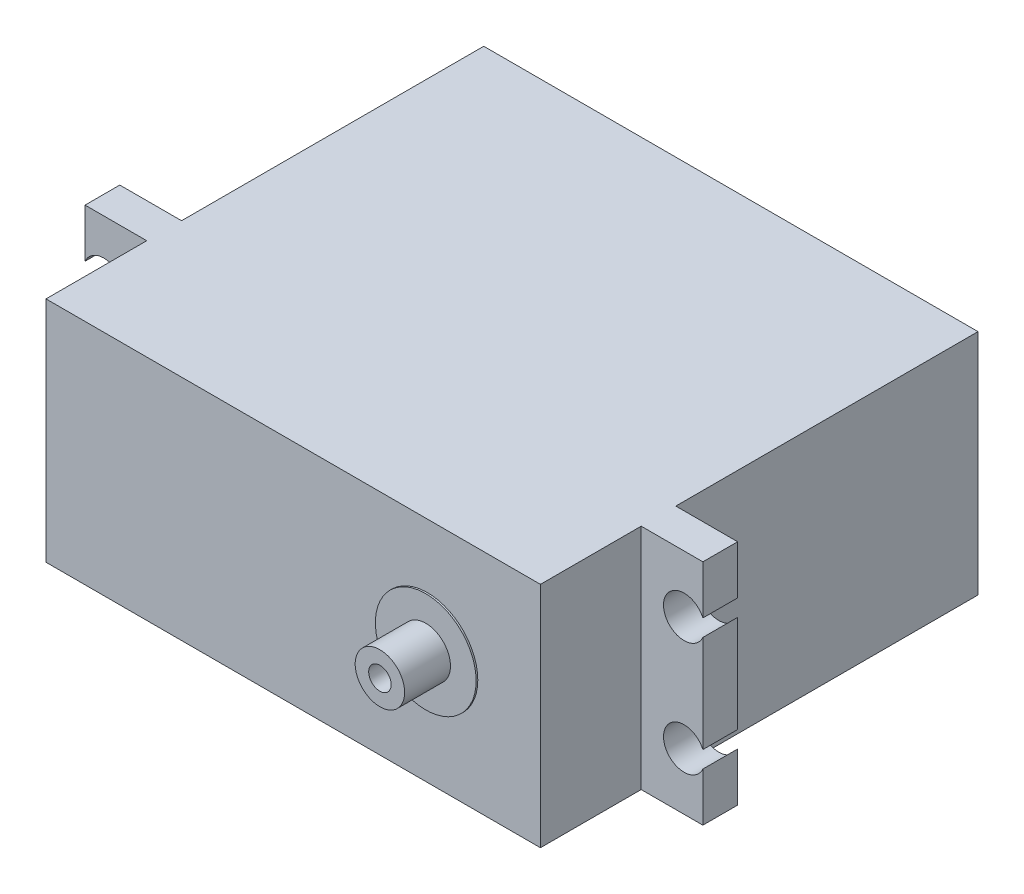
from build123d import *

# Parameters (mm, degrees)
SKETCH_1_W       = 66.04
SKETCH_1_H       = 30.48
EXTRUDE_1_DEPTH  = 40.3754
EXTRUDE_11_DEPTH = 4.64
SKETCH_3_W       = 66.06472
SKETCH_3_H       = 30.48
EXTRUDE_12_DEPTH = 13.462
SKETCH_5_R       = 6.731
SKETCH_5_R_2     = 3.302
EXTRUDE_13_DEPTH = 0.22537
SKETCH_6_R       = 3.302
SKETCH_6_R_2     = 1.5
EXTRUDE_14_DEPTH = 6.35


with BuildPart() as part:
    # 스케치1 → 보스-돌출1 (new body)
    with BuildSketch(Plane.XY):
        Rectangle(SKETCH_1_W, SKETCH_1_H)
    extrude(amount=EXTRUDE_1_DEPTH)

    # 스케치2 → 보스-돌출11 (add)
    with BuildSketch(Plane.XY.offset(40.3754)):
        with BuildLine():
            Line((41.275, -8.74168445), (41.275, -15.24))
            Line((41.275, -15.24), (-41.275, -15.24))
            Line((-41.275, -15.24), (-41.275, -8.74168445))
            ThreePointArc((-41.275, -8.74168445), (-36.01612, -7.61562), (-41.275, -6.48955555))
            Line((-41.275, -6.48955555), (-41.275, 6.48955555))
            ThreePointArc((-41.275, 6.48955555), (-36.01612, 7.61562), (-41.275, 8.74168445))
            Line((-41.275, 8.74168445), (-41.275, 15.24))
            Line((-41.275, 15.24), (41.275, 15.24))
            Line((41.275, 15.24), (41.275, 8.74168445))
            ThreePointArc((41.275, 8.74168445), (36.01612, 7.61562), (41.275, 6.48955555))
            Line((41.275, 6.48955555), (41.275, -6.48955555))
            ThreePointArc((41.275, -6.48955555), (36.01612, -7.61562), (41.275, -8.74168445))
        make_face()
    extrude(amount=EXTRUDE_11_DEPTH)

    # 스케치3 → 보스-돌출12 (add)
    with BuildSketch(Plane.XY.offset(45.0154)):
        Rectangle(SKETCH_3_W, SKETCH_3_H)
    extrude(amount=EXTRUDE_12_DEPTH)

    # 스케치5 → 보스-돌출13 (add)
    with BuildSketch(Plane.XY.offset(58.4774)):
        with Locations((17.9325, 0)):
            Circle(SKETCH_5_R)
        with Locations((17.9325, 0)):
            Circle(SKETCH_5_R_2, mode=Mode.SUBTRACT)
    extrude(amount=EXTRUDE_13_DEPTH)

    # 스케치6 → 보스-돌출14 (add)
    with BuildSketch(Plane.XY.offset(58.4774)):
        with Locations((17.9325, 0)):
            Circle(SKETCH_6_R)
        with Locations((17.9325, 0)):
            Circle(SKETCH_6_R_2, mode=Mode.SUBTRACT)
    extrude(amount=EXTRUDE_14_DEPTH)


solid = part.part
